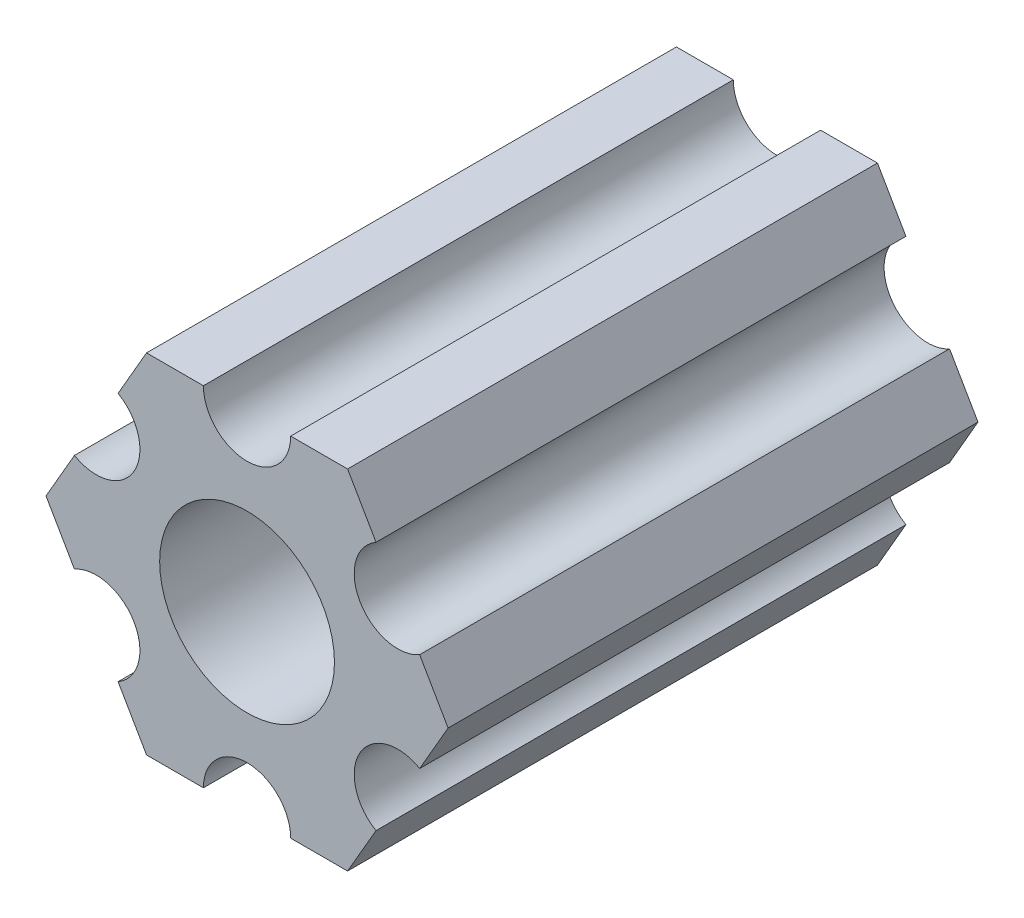
from build123d import *

# Parameters (mm, degrees)
SKETCH1_R           = 2.9337
BOSS_EXTRUDE1_DEPTH = 19.325
MOVE_FACE1_BY       = 0.254


with BuildPart() as part:
    # Sketch1 → Boss-Extrude1 (new body)
    with BuildSketch(Plane(origin=(0, 0, 0), x_dir=(-1, 0, 0), z_dir=(0, 0, -1))):
        with BuildLine():
            Line((-4.703606334, -4.55311485), (-3.666174209, -6.35))
            Line((-3.666174209, -6.35), (-1.591309959, -6.35))
            ThreePointArc((-1.591309959, -6.35), (0, -4.758690041), (1.591309959, -6.35))
            Line((1.591309959, -6.35), (3.666174209, -6.35))
            Line((3.666174209, -6.35), (4.703606334, -4.55311485))
            ThreePointArc((4.703606334, -4.55311485), (4.121146464, -2.37934502), (6.294916294, -1.79688515))
            Line((6.294916294, -1.79688515), (7.332348419, 0))
            Line((7.332348419, 0), (6.294916294, 1.79688515))
            ThreePointArc((6.294916294, 1.79688515), (4.121146464, 2.37934502), (4.703606334, 4.55311485))
            Line((4.703606334, 4.55311485), (3.666174209, 6.35))
            Line((3.666174209, 6.35), (1.591309959, 6.35))
            ThreePointArc((1.591309959, 6.35), (0, 4.758690041), (-1.591309959, 6.35))
            Line((-1.591309959, 6.35), (-3.666174209, 6.35))
            Line((-3.666174209, 6.35), (-4.703606334, 4.55311485))
            ThreePointArc((-4.703606334, 4.55311485), (-4.121146464, 2.37934502), (-6.294916294, 1.79688515))
            Line((-6.294916294, 1.79688515), (-7.332348419, 0))
            Line((-7.332348419, 0), (-6.294916294, -1.79688515))
            ThreePointArc((-6.294916294, -1.79688515), (-4.121146464, -2.37934502), (-4.703606334, -4.55311485))
        make_face()
        with Locations(Location((0, 0, 0), (0, 0, 180))):
            Circle(SKETCH1_R, mode=Mode.SUBTRACT)
    extrude(amount=-BOSS_EXTRUDE1_DEPTH)

    # Move Face1: a curved face moved inward by 0.254
    add(Solid.thicken(part.faces().sort_by_distance((-2.9337, 0, 9.6625))[0], -MOVE_FACE1_BY), mode=Mode.SUBTRACT)


solid = part.part
